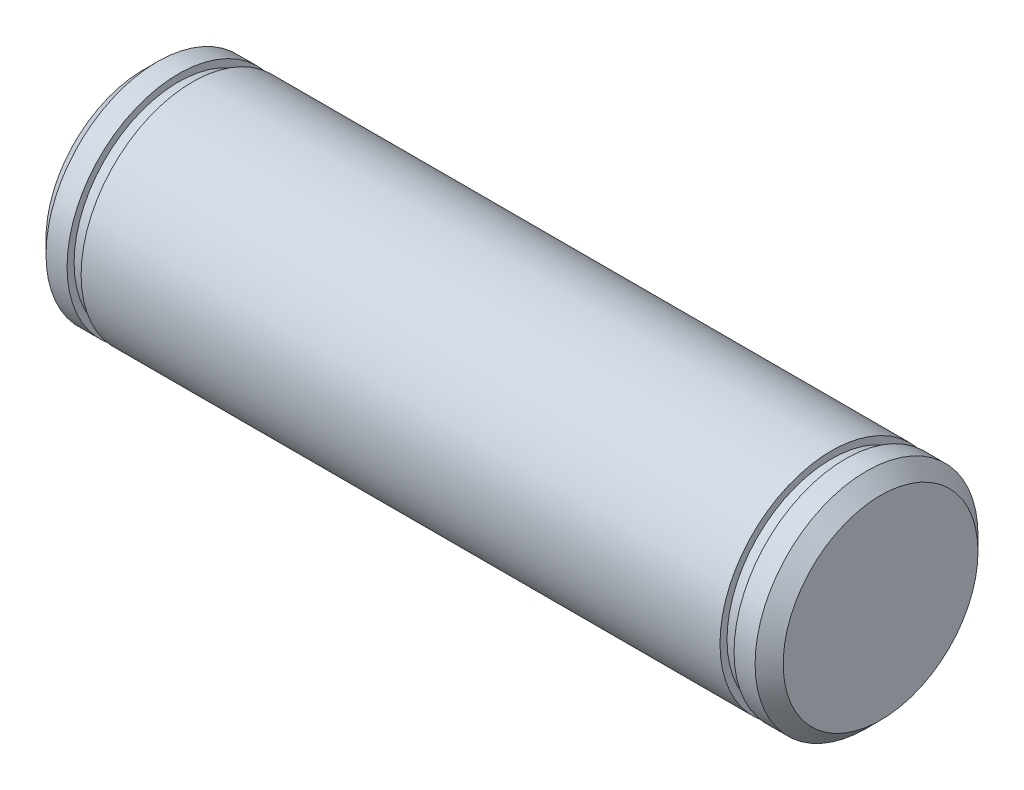
from build123d import *

# Parameters (mm, degrees)
SKETCH1_R           = 15.875
BOSS_EXTRUDE1_DEPTH = 52.5
CHAMFER1_SIZE       = 2
SKETCH2_R           = 15.875
SKETCH2_R_2         = 14.875
CUT_EXTRUDE1_DEPTH  = 2


with BuildPart() as part:
    # Sketch1 → Boss-Extrude1 (new body, symmetric)
    with BuildSketch(Plane(origin=(0, 0, 0), x_dir=(0, 0, -1), z_dir=(1, 0, 0))):
        Circle(SKETCH1_R)
    extrude(amount=BOSS_EXTRUDE1_DEPTH, both=True)

    # Chamfer1
    chamfer1_edges = [part.edges().sort_by_distance(p)[0] for p in [
        (-52.5, 0, 15.875),
        (52.5, 0, 15.875),
    ]]
    chamfer(chamfer1_edges, length=CHAMFER1_SIZE)

    # Sketch2 → Cut-Extrude1 (cut)
    with BuildSketch(Plane.ZY.offset(47.5)):
        Circle(SKETCH2_R)
        Circle(SKETCH2_R_2, mode=Mode.SUBTRACT)
    cut_extrude1 = extrude(amount=-CUT_EXTRUDE1_DEPTH, mode=Mode.SUBTRACT)

    # Mirror1: Cut-Extrude1 across plane
    add(cut_extrude1.mirror(Plane(origin=(0, 0, 0), x_dir=(0, 0, 1), z_dir=(1, 0, 0))), mode=Mode.SUBTRACT)


solid = part.part
